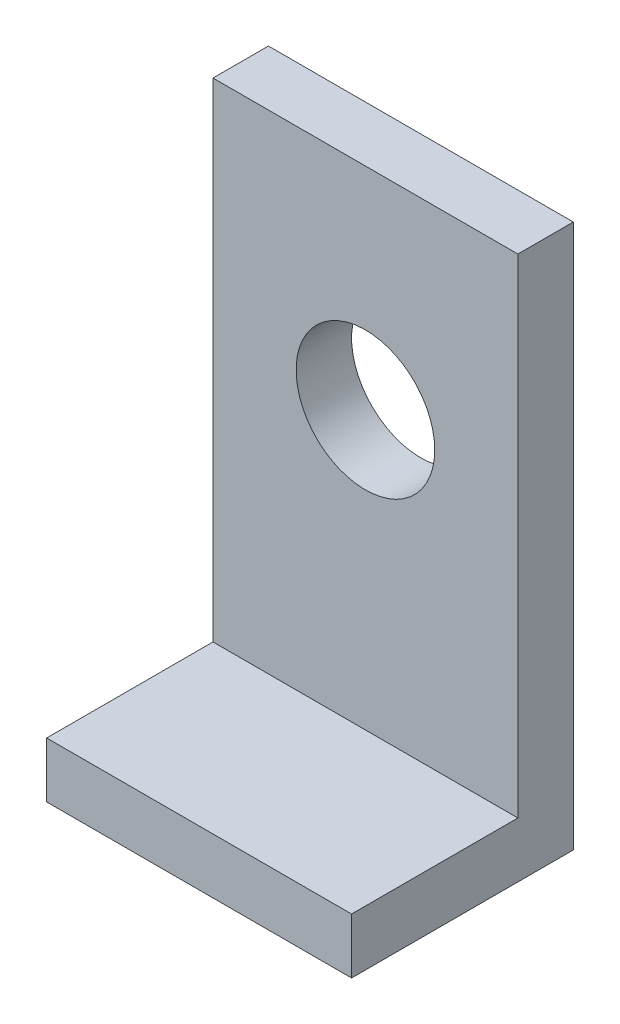
from build123d import *

# Parameters (mm, degrees)
CROQUIS1_R              = 12.5
SALIENTE_EXTRUIR1_DEPTH = 10
CROQUIS2_W              = 55
CROQUIS2_H              = 10
SALIENTE_EXTRUIR2_DEPTH = 30


with BuildPart() as part:
    # Croquis1 → Saliente-Extruir1 (new body)
    with BuildSketch(Plane.XY):
        Polygon((0, 98.1), (27.5, 98.1), (27.5, 0), (-27.5, 0), (-27.5, 98.1), align=None)
        with Locations((0, 60)):
            Circle(CROQUIS1_R, mode=Mode.SUBTRACT)
    extrude(amount=SALIENTE_EXTRUIR1_DEPTH)

    # Croquis2 → Saliente-Extruir2 (add)
    with BuildSketch(Plane.XY.offset(10)):
        with Locations((0, 5)):
            Rectangle(CROQUIS2_W, CROQUIS2_H)
    extrude(amount=SALIENTE_EXTRUIR2_DEPTH)


solid = part.part
